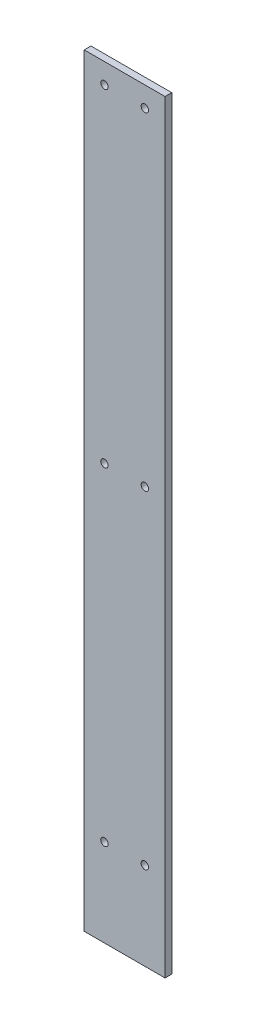
from build123d import *

# Parameters (mm, degrees)
ESQUISSE1_W        = 60
ESQUISSE1_H        = 567
ESQUISSE1_R        = 2.75
BOSS_EXTRU_1_DEPTH = 5


with BuildPart() as part:
    # Esquisse1 → Boss.-Extru.1 (new body)
    with BuildSketch(Plane.XY):
        with Locations((30, 283.5)):
            Rectangle(ESQUISSE1_W, ESQUISSE1_H)
        with Locations((15, 552)):
            Circle(ESQUISSE1_R, mode=Mode.SUBTRACT)
        with Locations((45, 552)):
            Circle(ESQUISSE1_R, mode=Mode.SUBTRACT)
        with Locations((45, 308.5)):
            Circle(ESQUISSE1_R, mode=Mode.SUBTRACT)
        with Locations((15, 308.5)):
            Circle(ESQUISSE1_R, mode=Mode.SUBTRACT)
        with Locations((45, 65)):
            Circle(ESQUISSE1_R, mode=Mode.SUBTRACT)
        with Locations((15, 65)):
            Circle(ESQUISSE1_R, mode=Mode.SUBTRACT)
    extrude(amount=BOSS_EXTRU_1_DEPTH)


solid = part.part
